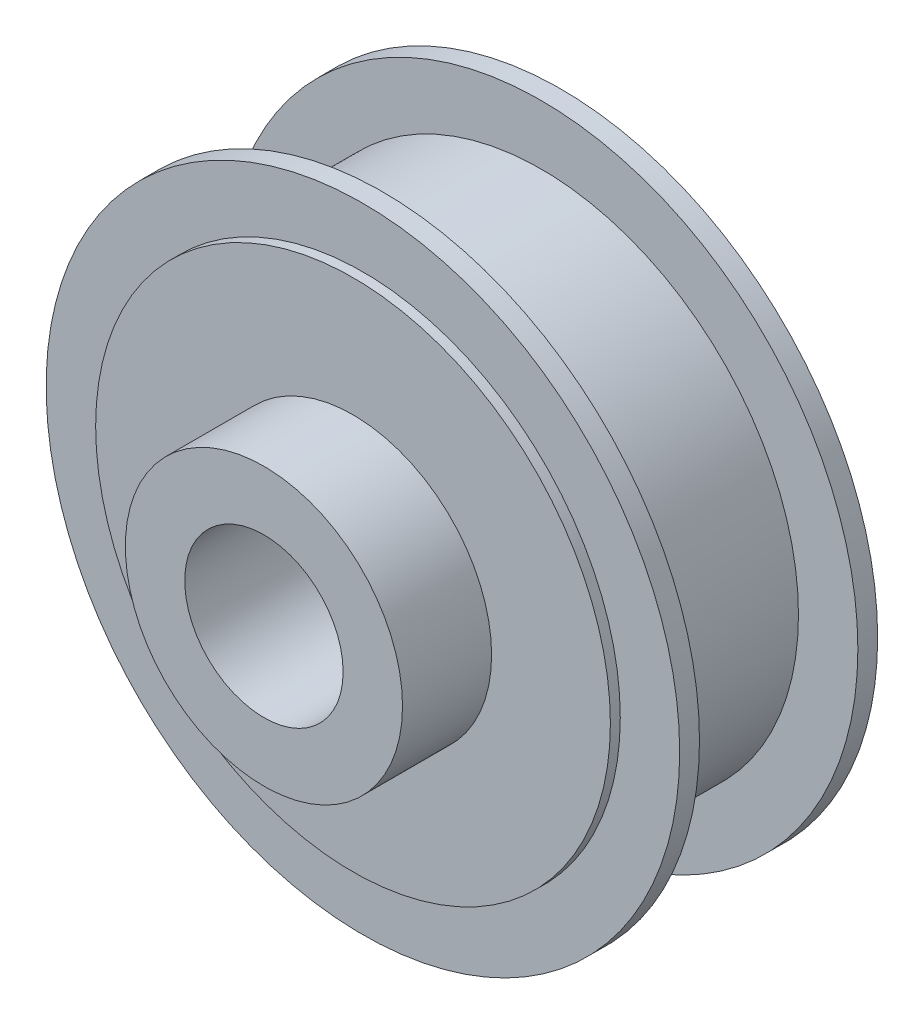
from build123d import *

# Parameters (mm, degrees)
ESQUISSE1_R             = 16
BOSS_EXTRU_1_DEPTH      = 1
ESQUISSE2_R             = 13
BOSS_EXTRU_2_DEPTH      = 8
ESQUISSE3_R             = 16
BOSS_EXTRU_3_DEPTH      = 1
ESQUISSE4_R             = 7
BOSS_EXTRU_4_DEPTH      = 5
ESQUISSE6_R             = 13
BOSS_EXTRU_5_DEPTH      = 0.5
ESQUISSE7_R             = 13
BOSS_EXTRU_6_DEPTH      = 0.5
ESQUISSE8_R             = 4
ENL_V_MAT_EXTRU_2_DEPTH = 16


with BuildPart() as part:
    # Esquisse1 → Boss.-Extru.1 (new body)
    with BuildSketch(Plane.XY):
        Circle(ESQUISSE1_R)
    extrude(amount=BOSS_EXTRU_1_DEPTH)

    # Esquisse2 → Boss.-Extru.2 (add)
    with BuildSketch(Plane.XY.offset(1)):
        Circle(ESQUISSE2_R)
    extrude(amount=BOSS_EXTRU_2_DEPTH)

    # Esquisse3 → Boss.-Extru.3 (add)
    with BuildSketch(Plane.XY.offset(9)):
        Circle(ESQUISSE3_R)
    extrude(amount=BOSS_EXTRU_3_DEPTH)

    # Esquisse4 → Boss.-Extru.4 (add)
    with BuildSketch(Plane.XY.offset(10)):
        Circle(ESQUISSE4_R)
    extrude(amount=BOSS_EXTRU_4_DEPTH)

    # Esquisse6 → Boss.-Extru.5 (add)
    with BuildSketch(Plane.XY.offset(10)):
        Circle(ESQUISSE6_R)
    extrude(amount=BOSS_EXTRU_5_DEPTH)

    # Esquisse7 → Boss.-Extru.6 (add)
    with BuildSketch(Plane(origin=(0, 0, 0), x_dir=(-1, 0, 0), z_dir=(0, 0, -1))):
        Circle(ESQUISSE7_R)
    extrude(amount=BOSS_EXTRU_6_DEPTH)

    # Esquisse8 → Enlèv. mat.-Extru.2 (cut)
    with BuildSketch(Plane.XY.offset(15)):
        Circle(ESQUISSE8_R)
    extrude(amount=-ENL_V_MAT_EXTRU_2_DEPTH, mode=Mode.SUBTRACT)


solid = part.part
